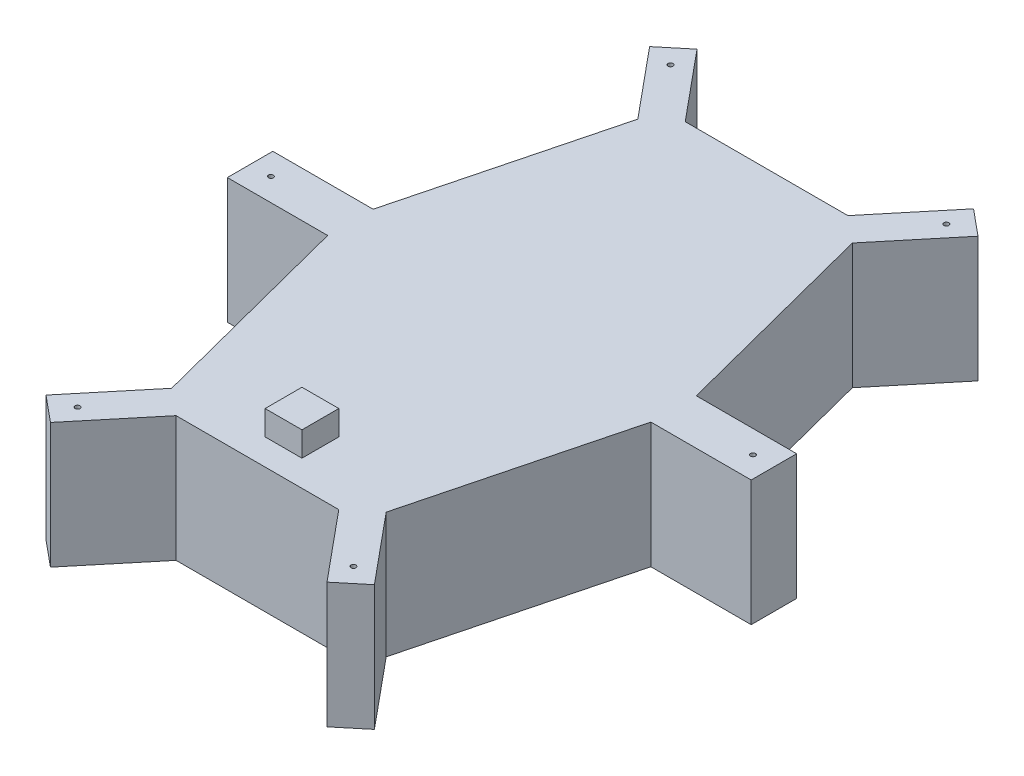
from build123d import *

# Parameters (mm, degrees)
EXTRUDE_1_DEPTH          = 51
SKETCH_2_R               = 1
CUT_EXTRUDE_1_DEPTH      = 51
SKETCH_3_R               = 1
CUT_EXTRUDE_2_DEPTH      = 51
MIRROR_3_COPY_1_SKETCH_R = 1
MIRROR_3_COPY_1_DEPTH    = 51
SKETCH_4_W               = 15
SKETCH_4_H               = 15
EXTRUDE_2_DEPTH          = 10


with BuildPart() as part:
    # 草图1 → 凸台-拉伸1 (new body)
    with BuildSketch(Plane(origin=(0, 0, 0), x_dir=(1, 0, 0), z_dir=(0, 1, 0))):
        Polygon((43.65, -94.842931951), (65.75, -9.25), (106.567585168, -9.25), (106.567585168, 9.25), (65.75, 9.25), (43.65, 94.842931951), (66.809562052, 122.798714511), (56.259562052, 131.538708791), (33.1, 103.58292623), (-33.1, 103.58292623), (-56.259562052, 131.538708791), (-66.809562052, 122.798714511), (-43.65, 94.842931951), (-65.75, 9.25), (-106.567585168, 9.25), (-106.567585168, -9.25), (-65.75, -9.25), (-43.65, -94.842931951), (-66.809562052, -122.798714511), (-56.259562052, -131.538708791), (-33.1, -103.58292623), (33.1, -103.58292623), (56.259562052, -131.538708791), (66.809562052, -122.798714511), align=None)
    extrude(amount=EXTRUDE_1_DEPTH)

    # 草图2 → 切除-拉伸1 (cut)
    with BuildSketch(Plane.XZ):
        with Locations((98.067585168, 0)):
            Circle(SKETCH_2_R)
    cut_extrude_1 = extrude(amount=-CUT_EXTRUDE_1_DEPTH, mode=Mode.SUBTRACT)

    # 镜向1: 切除-拉伸1 across plane
    add(cut_extrude_1.mirror(Plane(origin=(0, 0, 0), x_dir=(0, 0, 1), z_dir=(1, 0, 0))), mode=Mode.SUBTRACT)

    # 草图3 → 切除-拉伸2 (cut)
    with BuildSketch(Plane.XZ):
        with Locations((56.111937864, 120.623091213)):
            Circle(SKETCH_3_R)
    cut_extrude_2 = extrude(amount=-CUT_EXTRUDE_2_DEPTH, mode=Mode.SUBTRACT)

    # 镜向2: 切除-拉伸2 across plane
    add(cut_extrude_2.mirror(Plane(origin=(0, 0, 0), x_dir=(0, 0, 1), z_dir=(1, 0, 0))), mode=Mode.SUBTRACT)

    # 镜向3: 切除-拉伸2 across plane
    add(cut_extrude_2.mirror(Plane.XY), mode=Mode.SUBTRACT)

    # 镜向3 copy 1 sketch → 镜向3 copy 1 (cut)
    with BuildSketch(Plane(origin=(0, 0, 0), x_dir=(-1, 0, 0), z_dir=(0, -1, 0))):
        with Locations((56.111937864, 120.623091213)):
            Circle(MIRROR_3_COPY_1_SKETCH_R)
    extrude(amount=-MIRROR_3_COPY_1_DEPTH, mode=Mode.SUBTRACT)

    # 草图4 → 凸台-拉伸2 (add)
    with BuildSketch(Plane.XZ.offset(-51)):
        with Locations((0, 85.462689848)):
            Rectangle(SKETCH_4_W, SKETCH_4_H)
    extrude(amount=-EXTRUDE_2_DEPTH)


solid = part.part
